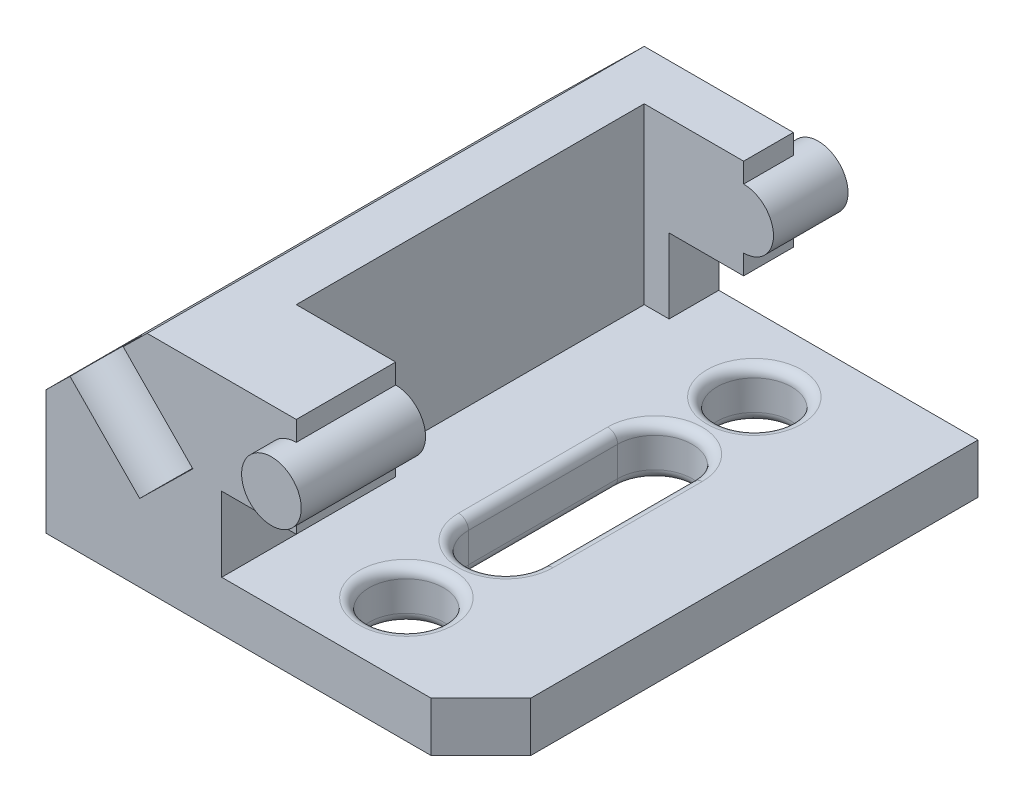
from build123d import *

# Parameters (mm, degrees)
BOSS_EXTRUDE1_DEPTH      = 100
SKETCH2_R                = 6
BOSS_EXTRUDE3_DEPTH      = 5
BOSS_EXTRUDE3_DEPTH_BACK = 105
SKETCH3_W                = 26
SKETCH3_H                = 70
CUT_EXTRUDE2_DEPTH       = 35
SKETCH4_R                = 7.5
CUT_EXTRUDE3_DEPTH       = 10
CUT_EXTRUDE4_DEPTH       = 20
CHAMFER1_SIZE            = 10
FILLET1_R                = 2


with BuildPart() as part:
    # Sketch1 → Boss-Extrude1 (new body)
    with BuildSketch(Plane.XY):
        Polygon((-87.5, 0), (0, 0), (0, 10), (-52.147852141, 10), (-52.147852141, 25), (-37.147852141, 25), (-37.147852141, 45), (-67.147852141, 45), (-87.5, 25), align=None)
    extrude(amount=BOSS_EXTRUDE1_DEPTH)

    # Sketch2 → Boss-Extrude3 (add, two sides)
    with BuildSketch(Plane.XY.offset(100)) as boss_extrude3_sk:
        with Locations((-37.147852141, 35)):
            Circle(SKETCH2_R)
    extrude(amount=BOSS_EXTRUDE3_DEPTH)
    extrude(boss_extrude3_sk.sketch, amount=-BOSS_EXTRUDE3_DEPTH_BACK)

    # Sketch3 → Cut-Extrude2 (cut)
    with BuildSketch(Plane(origin=(0, 45, 0), x_dir=(1, 0, 0), z_dir=(0, 1, 0))):
        with Locations((-44.147852141, -45)):
            Rectangle(SKETCH3_W, SKETCH3_H)
    extrude(amount=-CUT_EXTRUDE2_DEPTH, mode=Mode.SUBTRACT)

    # Sketch4 → Cut-Extrude3 (cut)
    with BuildSketch(Plane(origin=(0, 10, 0), x_dir=(1, 0, 0), z_dir=(0, 1, 0))):
        with Locations((-30, -85)):
            Circle(SKETCH4_R)
        with Locations((-30, -15)):
            Circle(SKETCH4_R)
        with BuildLine():
            Line((-37.5, -65), (-37.5, -35))
            ThreePointArc((-37.5, -35), (-30, -27.5), (-22.5, -35))
            Line((-22.5, -35), (-22.5, -65))
            ThreePointArc((-22.5, -65), (-30, -72.5), (-37.5, -65))
        make_face()
    extrude(amount=-CUT_EXTRUDE3_DEPTH, mode=Mode.SUBTRACT)

    # Sketch5 → Cut-Extrude4 (cut)
    with BuildSketch(Plane(origin=(-55.484553408, 56.461491744, 0), x_dir=(0.713250449, 0.700909264, 0), z_dir=(-0.700909264, 0.713250449, 0))):
        with BuildLine():
            Line((-38.119500749, -100), (-23.119500749, -100))
            ThreePointArc((-23.119500749, -100), (-30.619500749, -92.5), (-38.119500749, -100))
        make_face()
    extrude(amount=-CUT_EXTRUDE4_DEPTH, mode=Mode.SUBTRACT)

    # Chamfer1
    chamfer1_edges = [part.edges().sort_by_distance(p)[0] for p in [
        (0, 5, 100),
    ]]
    chamfer(chamfer1_edges, length=CHAMFER1_SIZE)

    # Fillet1
    fillet1_edges = [part.edges().sort_by_distance(p)[0] for p in [
        (-37.5, 10, 85),
        (-37.5, 0, 85),
        (-37.5, 10, 15),
        (-37.5, 0, 15),
        (-30, 10, 72.5),
        (-22.5, 10, 50),
        (-30, 10, 27.5),
        (-37.5, 10, 50),
        (-30, 0, 72.5),
        (-37.5, 0, 50),
        (-30, 0, 27.5),
        (-22.5, 0, 50),
    ]]
    fillet(fillet1_edges, radius=FILLET1_R)


solid = part.part
